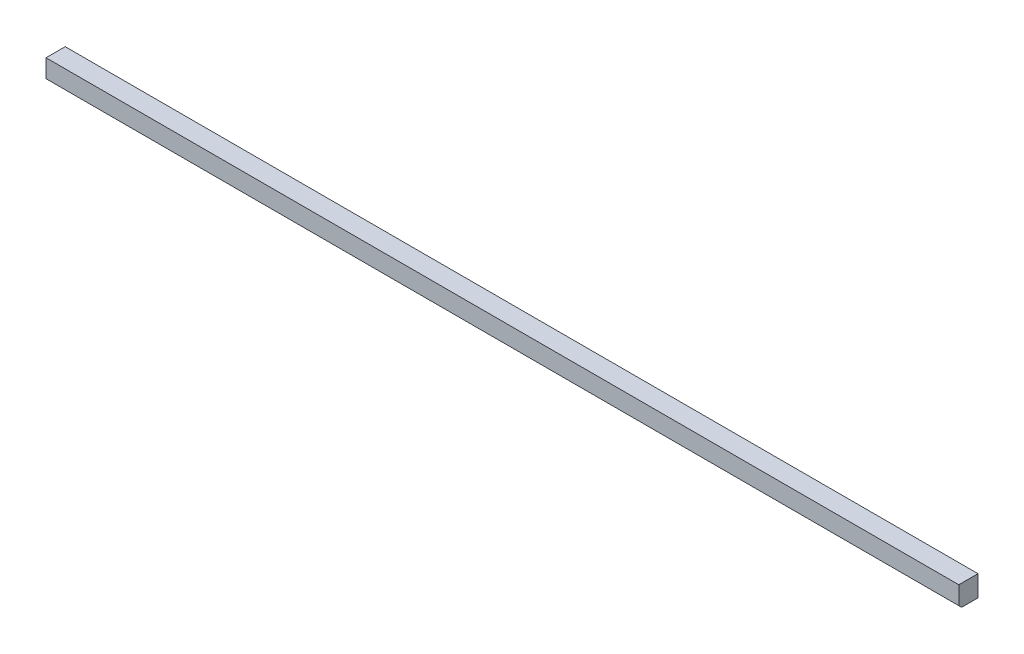
from build123d import *

# Parameters (mm, degrees)
SKETCH1_W           = 830.2625
SKETCH1_H           = 17.4625
BOSS_EXTRUDE1_DEPTH = 19.05
CHAMFER1_SIZE       = 2.54


with BuildPart() as part:
    # Sketch1 → Boss-Extrude1 (new body)
    with BuildSketch(Plane(origin=(0, 0, 0), x_dir=(1, 0, 0), z_dir=(0, 1, 0))):
        with Locations((415.13125, 8.73125)):
            Rectangle(SKETCH1_W, SKETCH1_H)
    extrude(amount=BOSS_EXTRUDE1_DEPTH)

    # Chamfer1
    chamfer1_edges = [part.edges().sort_by_distance(p)[0] for p in [
        (415.13125, 0, 0),
    ]]
    chamfer(chamfer1_edges, length=CHAMFER1_SIZE)


solid = part.part
